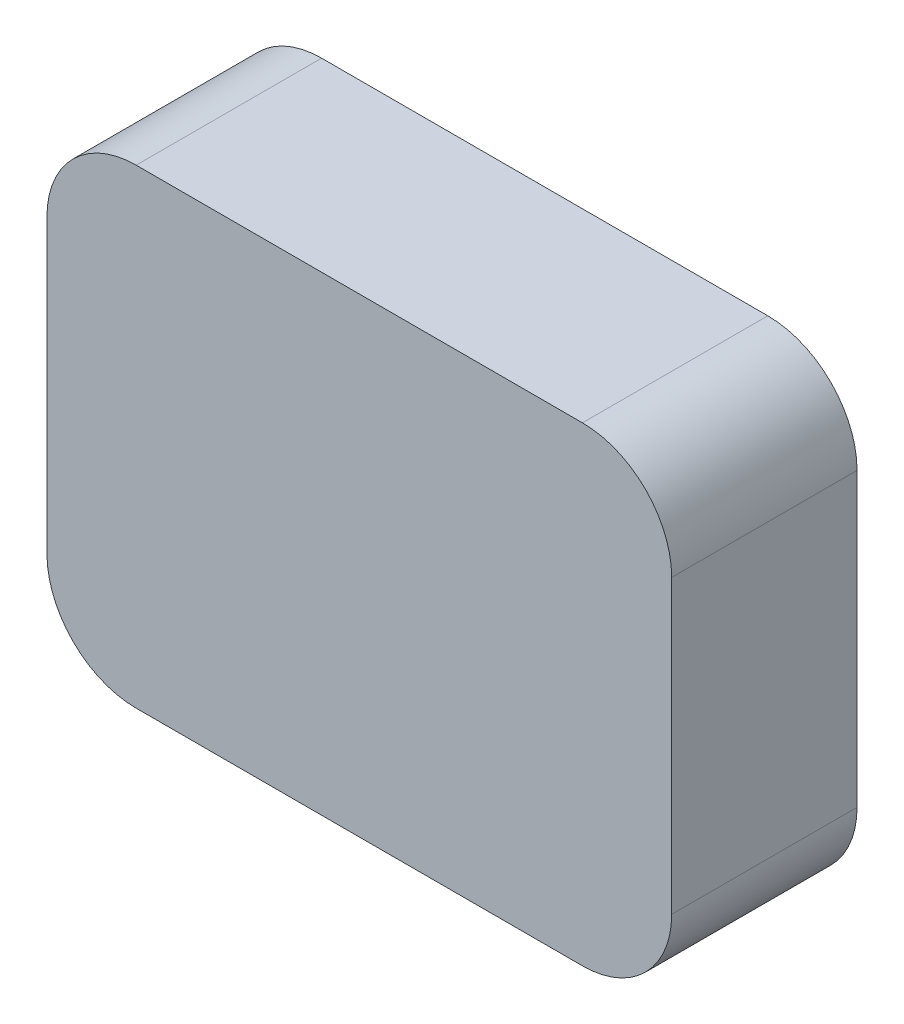
from build123d import *

# Parameters (mm, degrees)
BOSS_EXTRU_1_DEPTH      = 1.6
CONG_1_R                = 2
EXTRU_MINCE1_DEPTH      = 1.6
EXTRU_MINCE1_DEPTH_BACK = 20


with BuildPart() as part:
    # Balayage1: sweep along a path in Esquisse1
    with BuildLine(Plane.XY) as balayage1_path:
        Line((-26, 27), (26, 27))
        ThreePointArc((26, 27), (33.071067812, 24.071067812), (36, 17))
        Line((36, 17), (36, -17))
        ThreePointArc((36, -17), (33.071067812, -24.071067812), (26, -27))
        Line((26, -27), (-26, -27))
        ThreePointArc((-26, -27), (-33.071067812, -24.071067812), (-36, -17))
        Line((-36, -17), (-36, 17))
        ThreePointArc((-36, 17), (-33.071067812, 24.071067812), (-26, 27))
    # profil → Balayage1 (sweep)
    with BuildSketch(Plane(origin=(0, 0, 0), x_dir=(0, 0, -1), z_dir=(1, 0, 0))):
        Polygon((0, -25.521907401), (4.110600662, -25.521907401), (10, -21), (10, -21.4), (9.8, -21.4), (9.8, -22.2), (10, -22.2), (10, -22.6), (10.4, -22.6), (10.4, -23), (10.8, -23), (10.8, -23.4), (11.2, -23.4), (11.2, -23.8), (11.6, -23.8), (11.6, -24.2), (11.2, -24.2), (11.2, -24.6), (10.8, -24.6), (10.8, -25), (10.4, -25), (10.4, -25.4), (10, -25.4), (10, -25.8), (9.8, -25.8), (9.8, -26.6), (10, -26.6), (10, -27), (0, -27), align=None)
    sweep(path=balayage1_path.line)

    # Esquisse1_3 → Boss.-Extru.1 (add)
    with BuildSketch(Plane.XY):
        with BuildLine():
            Line((-26, 27), (26, 27))
            ThreePointArc((26, 27), (33.071067812, 24.071067812), (36, 17))
            Line((36, 17), (36, -17))
            ThreePointArc((36, -17), (33.071067812, -24.071067812), (26, -27))
            Line((26, -27), (-26, -27))
            ThreePointArc((-26, -27), (-33.071067812, -24.071067812), (-36, -17))
            Line((-36, -17), (-36, 17))
            ThreePointArc((-36, 17), (-33.071067812, 24.071067812), (-26, 27))
        make_face()
    extrude(amount=BOSS_EXTRU_1_DEPTH)

    # Congé1
    cong_1_edges = [part.edges().sort_by_distance(p)[0] for p in [
        (34.521907401, 0, 0),
        (32.025898512, -23.025898512, 0),
        (0, -25.521907401, 0),
        (-32.025898512, -23.025898512, 0),
        (-34.521907401, 0, 0),
        (-32.025898512, 23.025898512, 0),
        (0, 25.521907401, 0),
        (0, -25.521907401, 0),
        (32.025898512, 23.025898512, 0),
    ]]
    fillet(cong_1_edges, radius=CONG_1_R)

    # Esquisse2 → Extru.-Mince1 (add, two sides)
    with BuildSketch(Plane.XY) as extru_mince1_sk:
        with BuildLine():
            Line((-36.4, 17), (-36.4, -17))
            ThreePointArc((-36.4, -17), (-33.353910524, -24.353910524), (-26, -27.4))
            Line((-26, -27.4), (26, -27.4))
            ThreePointArc((26, -27.4), (33.353910524, -24.353910524), (36.4, -17))
            Line((36.4, -17), (36.4, 17))
            ThreePointArc((36.4, 17), (33.353910524, 24.353910524), (26, 27.4))
            Line((26, 27.4), (-26, 27.4))
            ThreePointArc((-26, 27.4), (-33.353910524, 24.353910524), (-36.4, 17))
        make_face()
        with BuildLine():
            Line((-36, 17), (-36, -17))
            ThreePointArc((-36, -17), (-33.071067812, -24.071067812), (-26, -27))
            Line((-26, -27), (26, -27))
            ThreePointArc((26, -27), (33.071067812, -24.071067812), (36, -17))
            Line((36, -17), (36, 17))
            ThreePointArc((36, 17), (33.071067812, 24.071067812), (26, 27))
            Line((26, 27), (-26, 27))
            ThreePointArc((-26, 27), (-33.071067812, 24.071067812), (-36, 17))
        make_face(mode=Mode.SUBTRACT)
    extrude(amount=EXTRU_MINCE1_DEPTH)
    extrude(extru_mince1_sk.sketch, amount=-EXTRU_MINCE1_DEPTH_BACK)


solid = part.part
